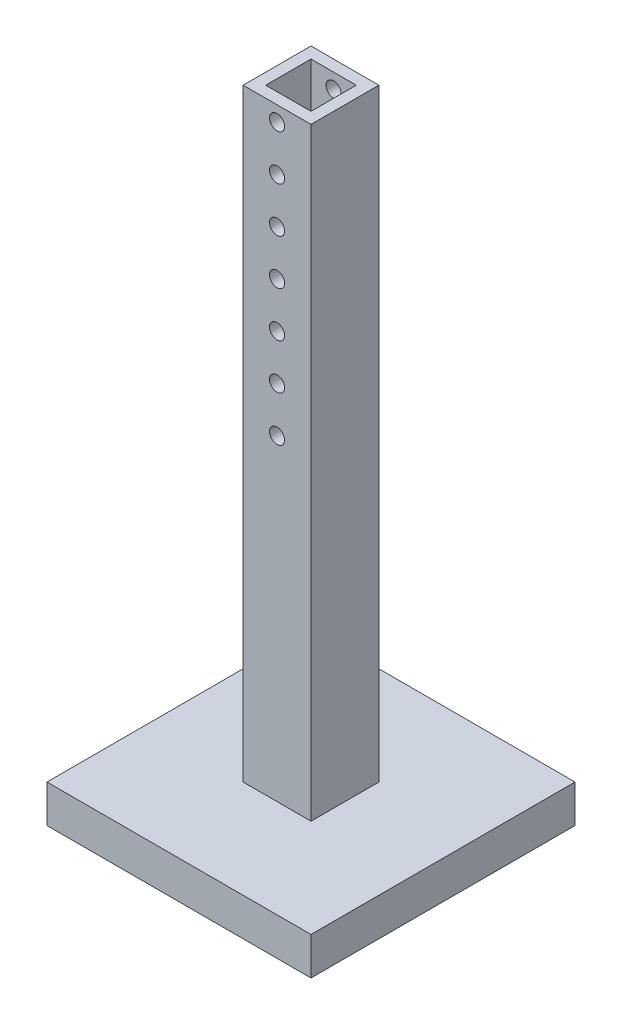
from build123d import *

# Parameters (mm, degrees)
SKETCH1_W           = 350
SKETCH1_H           = 350
BOSS_EXTRUDE1_DEPTH = 50
SKETCH2_W           = 90
SKETCH2_H           = 90
BOSS_EXTRUDE2_DEPTH = 800
SKETCH3_W           = 60
SKETCH3_H           = 60
CUT_EXTRUDE1_DEPTH  = 800
SKETCH4_R           = 10
CUT_EXTRUDE3_DEPTH  = 221


with BuildPart() as part:
    # Sketch1 → Boss-Extrude1 (new body)
    with BuildSketch(Plane(origin=(0, 0, 0), x_dir=(1, 0, 0), z_dir=(0, 1, 0))):
        Rectangle(SKETCH1_W, SKETCH1_H)
    extrude(amount=BOSS_EXTRUDE1_DEPTH)

    # Sketch2 → Boss-Extrude2 (add)
    with BuildSketch(Plane(origin=(0, 50, 0), x_dir=(1, 0, 0), z_dir=(0, 1, 0))):
        Rectangle(SKETCH2_W, SKETCH2_H)
    extrude(amount=BOSS_EXTRUDE2_DEPTH)

    # Sketch3 → Cut-Extrude1 (cut)
    with BuildSketch(Plane(origin=(0, 850, 0), x_dir=(1, 0, 0), z_dir=(0, 1, 0))):
        Rectangle(SKETCH3_W, SKETCH3_H)
    extrude(amount=-CUT_EXTRUDE1_DEPTH, mode=Mode.SUBTRACT)

    # Sketch4 → Cut-Extrude3 (cut, through all)
    with BuildSketch(Plane.XY.offset(45)):
        with Locations((0, 830)):
            Circle(SKETCH4_R)
        with Locations((0, 770)):
            Circle(SKETCH4_R)
        with Locations((0, 710)):
            Circle(SKETCH4_R)
        with Locations((0, 650)):
            Circle(SKETCH4_R)
        with Locations((0, 590)):
            Circle(SKETCH4_R)
        with Locations((0, 530)):
            Circle(SKETCH4_R)
        with Locations((0, 470)):
            Circle(SKETCH4_R)
    extrude(amount=-CUT_EXTRUDE3_DEPTH, mode=Mode.SUBTRACT)


solid = part.part
